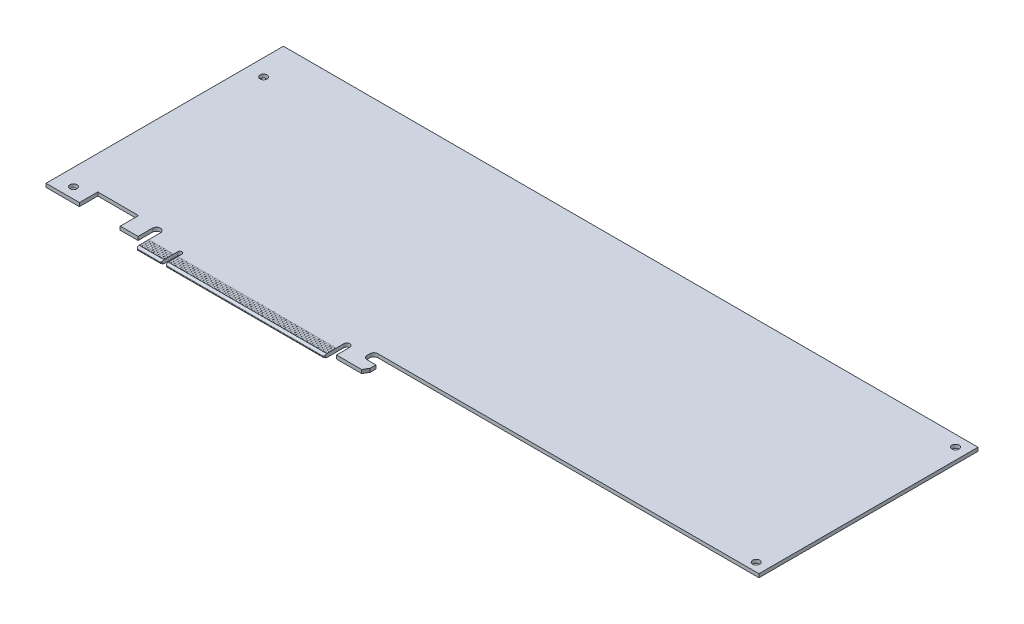
from build123d import *

# Parameters (mm, degrees)
SKETCH1_W                             = 312
SKETCH1_H                             = 111.15
BOSS_EXTRUDE1_DEPTH                   = 1.6
CUT_EXTRUDE1_REACH                    = 3.6
SKETCH2_W                             = 182.7
SKETCH2_H                             = 12.75
SKETCH3_W                             = 0.7
SKETCH3_H                             = 4.2
BOSS_EXTRUDE2_DEPTH                   = 0.035
BOSS_EXTRUDE2_DEPTH_BACK              = 1.635
BOSS_EXTRUDE2_2_DEPTH                 = 0.035
BOSS_EXTRUDE2_2_DEPTH_BACK            = 1.635
BOSS_EXTRUDE2_3_DEPTH                 = 0.035
BOSS_EXTRUDE2_3_DEPTH_BACK            = 1.635
BOSS_EXTRUDE2_4_DEPTH                 = 0.035
BOSS_EXTRUDE2_4_DEPTH_BACK            = 1.635
BOSS_EXTRUDE2_5_DEPTH                 = 0.035
BOSS_EXTRUDE2_5_DEPTH_BACK            = 1.635
BOSS_EXTRUDE2_6_DEPTH                 = 0.035
BOSS_EXTRUDE2_6_DEPTH_BACK            = 1.635
BOSS_EXTRUDE2_7_DEPTH                 = 0.035
BOSS_EXTRUDE2_7_DEPTH_BACK            = 1.635
BOSS_EXTRUDE2_8_DEPTH                 = 0.035
BOSS_EXTRUDE2_8_DEPTH_BACK            = 1.635
BOSS_EXTRUDE2_9_DEPTH                 = 0.035
BOSS_EXTRUDE2_9_DEPTH_BACK            = 1.635
BOSS_EXTRUDE2_10_DEPTH                = 0.035
BOSS_EXTRUDE2_10_DEPTH_BACK           = 1.635
BOSS_EXTRUDE2_11_DEPTH                = 0.035
BOSS_EXTRUDE2_11_DEPTH_BACK           = 1.635
SKETCH4_W                             = 0.7
SKETCH4_H                             = 4.2
BOSS_EXTRUDE3_DEPTH                   = 0.035
BOSS_EXTRUDE3_DEPTH_BACK              = 1.635
LPATTERN1_COUNT                       = 71
LPATTERN1_PITCH                       = 1
SKETCH6_W                             = 1.5875
SKETCH6_H                             = 1.6
F_1_8_0_125_DIAMETER_HOLE1_AT_2_COUNT = 2
F_1_8_0_125_DIAMETER_HOLE1_AT_2_PITCH = 85.4
SKETCH8_W                             = 1.5875
SKETCH8_H                             = 1.601
F_1_8_0_125_DIAMETER_HOLE2_AT_2_COUNT = 2
F_1_8_0_125_DIAMETER_HOLE2_AT_2_PITCH = 89.53
CHAMFER2_SIZE                         = 0.5
BOSS_EXTRUDE4_DEPTH                   = 1.6
CHAMFER3_SIZE                         = 0.6
CHAMFER3_SIZE2                        = 1.3
CHAMFER3_PART_2_SIZE                  = 0.6
CHAMFER3_PART_2_SIZE2                 = 1.3
CHAMFER5_SIZE                         = 1.3
CHAMFER5_SIZE2                        = 0.6
FILLET2_R                             = 0.2


with BuildPart() as part:
    # Sketch1 → Boss-Extrude1 (new body)
    with BuildSketch(Plane(origin=(0, 0, 0), x_dir=(1, 0, 0), z_dir=(0, 1, 0))):
        with Locations((156, 55.575)):
            Rectangle(SKETCH1_W, SKETCH1_H)
    extrude(amount=-BOSS_EXTRUDE1_DEPTH)

    # Sketch2 → Cut-Extrude1 (cut, up to next)
    with BuildSketch(Plane(origin=(0, 0, 0), x_dir=(1, 0, 0), z_dir=(0, 1, 0)), mode=Mode.PRIVATE) as cut_extrude1_sk1:
        with BuildLine():
            Line((0, 4.5), (15, 4.5))
            Line((15, 4.5), (15, 12.75))
            Line((15, 12.75), (33.35, 12.75))
            Line((33.35, 12.75), (33.35, 4.5))
            Line((33.35, 4.5), (41.35, 4.5))
            Line((41.35, 4.5), (41.35, 10.925))
            ThreePointArc((41.35, 10.925), (43.175, 12.75), (45, 10.925))
            Line((45, 10.925), (45, 0))
            Line((45, 0), (0, 0))
            Line((0, 0), (0, 4.5))
        make_face()
    cut_extrude1_tool1 = extrude(cut_extrude1_sk1.sketch, amount=-CUT_EXTRUDE1_REACH, mode=Mode.PRIVATE) & part.part
    add(cut_extrude1_tool1.solids().sort_by_distance((24.712912, 0, -5.236732))[0], mode=Mode.SUBTRACT)
    # Sketch2 → Cut-Extrude1 (cut, up to next)
    with BuildSketch(Plane(origin=(0, 0, 0), x_dir=(1, 0, 0), z_dir=(0, 1, 0)), mode=Mode.PRIVATE) as cut_extrude1_sk2:
        with BuildLine():
            Line((56.2, 0), (56.2, 7.45))
            ThreePointArc((56.2, 7.45), (57.15, 8.4), (58.1, 7.45))
            Line((58.1, 7.45), (58.1, 0))
            Line((58.1, 0), (56.2, 0))
        make_face()
    cut_extrude1_tool2 = extrude(cut_extrude1_sk2.sketch, amount=-CUT_EXTRUDE1_REACH, mode=Mode.PRIVATE) & part.part
    add(cut_extrude1_tool2.solids().sort_by_distance((57.15, 0, -4.100807))[0], mode=Mode.SUBTRACT)
    # Sketch2 → Cut-Extrude1 (cut, up to next)
    with BuildSketch(Plane(origin=(0, 0, 0), x_dir=(1, 0, 0), z_dir=(0, 1, 0)), mode=Mode.PRIVATE) as cut_extrude1_sk3:
        with Locations((220.65, 6.375)):
            Rectangle(SKETCH2_W, SKETCH2_H)
    cut_extrude1_tool3 = extrude(cut_extrude1_sk3.sketch, amount=-CUT_EXTRUDE1_REACH, mode=Mode.PRIVATE) & part.part
    add(cut_extrude1_tool3.solids().sort_by_distance((220.65, 0, -6.375))[0], mode=Mode.SUBTRACT)

    # Sketch6 → 1/8 (0.125) Diameter Hole1 (revolve, cut)
    with BuildSketch(Plane(origin=(7.5, 0, -9.35), x_dir=(0, 0, 1), z_dir=(1, 0, 0))):
        with Locations((0.79375, 0.8)):
            Rectangle(SKETCH6_W, SKETCH6_H)
    f_1_8_0_125_diameter_hole1 = revolve(axis=Axis((7.5, 6.35, -9.35), (0, -1, 0)), mode=Mode.SUBTRACT)

    # 1/8 (0.125) Diameter Hole1 at 2: 1/8 (0.125) Diameter Hole1 ×2
    with Locations(*[(0, 0, -i * F_1_8_0_125_DIAMETER_HOLE1_AT_2_PITCH) for i in range(1, F_1_8_0_125_DIAMETER_HOLE1_AT_2_COUNT)]):
        add(f_1_8_0_125_diameter_hole1, mode=Mode.SUBTRACT)

    # Sketch8 → 1/8 (0.125) Diameter Hole2 (revolve, cut)
    with BuildSketch(Plane(origin=(306.92, 0, -16.6), x_dir=(0, 0, 1), z_dir=(1, 0, 0))):
        with Locations((0.79375, 0.8005)):
            Rectangle(SKETCH8_W, SKETCH8_H)
    f_1_8_0_125_diameter_hole2 = revolve(axis=Axis((306.92, 6.35, -16.6), (0, -1, 0)), mode=Mode.SUBTRACT)

    # 1/8 (0.125) Diameter Hole2 at 2: 1/8 (0.125) Diameter Hole2 ×2
    with Locations(*[(0, 0, -i * F_1_8_0_125_DIAMETER_HOLE2_AT_2_PITCH) for i in range(1, F_1_8_0_125_DIAMETER_HOLE2_AT_2_COUNT)]):
        add(f_1_8_0_125_diameter_hole2, mode=Mode.SUBTRACT)

    # Chamfer2
    chamfer2_edges = [part.edges().sort_by_distance(p)[0] for p in [
        (45, -0.8, 0),
        (58.1, -0.8, 0),
        (56.2, -0.8, 0),
        (129.3, -0.8, 0),
    ]]
    chamfer(chamfer2_edges, length=CHAMFER2_SIZE)

    # Sketch11 → Boss-Extrude4 (add)
    with BuildSketch(Plane(origin=(0, 0, 0), x_dir=(1, 0, 0), z_dir=(0, 1, 0))):
        with BuildLine():
            Line((144.75, 7.95), (140.8, 7.95))
            ThreePointArc((140.8, 7.95), (139.562563133, 8.462563133), (139.05, 9.7))
            Line((139.05, 9.7), (139.05, 11))
            ThreePointArc((139.05, 11), (139.562563133, 12.237436867), (140.8, 12.75))
            Line((140.8, 12.75), (139.05, 12.75))
            Line((139.05, 12.75), (129.3, 12.75))
            Line((129.3, 12.75), (129.3, 8.98))
            ThreePointArc((129.3, 8.98), (130.675, 10.355), (132.05, 8.98))
            Line((132.05, 8.98), (132.05, 2.95))
            Line((132.05, 2.95), (143.35, 2.95))
            Line((143.35, 2.95), (144.75, 5.374871131))
            Line((144.75, 5.374871131), (144.75, 7.95))
        make_face()
    extrude(amount=-BOSS_EXTRUDE4_DEPTH)

    # Chamfer3
    chamfer3_edges = [part.edges().sort_by_distance(p)[0] for p in [
        (93.7, 0, 0),
    ]]
    chamfer3_side = [part.faces().sort_by_distance(p)[0] for p in [
        (93.7, -0.8, 0),
    ]]
    chamfer(chamfer3_edges, length=CHAMFER3_SIZE, length2=CHAMFER3_SIZE2, reference=chamfer3_side[0])

    # Chamfer3 part 2
    chamfer3_part_2_edges = [part.edges().sort_by_distance(p)[0] for p in [
        (50.6, 0, 0),
    ]]
    chamfer3_part_2_side = [part.faces().sort_by_distance(p)[0] for p in [
        (50.6, -0.8, 0),
    ]]
    chamfer(chamfer3_part_2_edges, length=CHAMFER3_PART_2_SIZE, length2=CHAMFER3_PART_2_SIZE2, reference=chamfer3_part_2_side[0])

    # Chamfer5
    chamfer5_edges = [part.edges().sort_by_distance(p)[0] for p in [
        (93.7, -1.6, 0),
        (50.6, -1.6, 0),
    ]]
    chamfer5_side = [part.faces().sort_by_distance(p)[0] for p in [
        (152.851600823, -1.6, -59.623886114),
    ]]
    chamfer(chamfer5_edges, length=CHAMFER5_SIZE, length2=CHAMFER5_SIZE2, reference=chamfer5_side[0])

    # Fillet2
    fillet2_edges = [part.edges().sort_by_distance(p)[0] for p in [
        (93.7, -0.6, 0),
        (50.6, -0.6, 0),
        (93.7, -1, 0),
        (50.6, -1, 0),
    ]]
    fillet(fillet2_edges, radius=FILLET2_R)


with BuildPart() as body_2:
    # Sketch3 → Boss-Extrude2 (new body, two sides)
    with BuildSketch(Plane(origin=(0, 0, 0), x_dir=(1, 0, 0), z_dir=(0, 1, 0))) as boss_extrude2_sk:
        with Locations((45.6, 3.5)):
            Rectangle(SKETCH3_W, SKETCH3_H)
    extrude(amount=BOSS_EXTRUDE2_DEPTH)
    extrude(boss_extrude2_sk.sketch, amount=-BOSS_EXTRUDE2_DEPTH_BACK)


with BuildPart() as body_3:
    # Sketch3 → Boss-Extrude2 2 (new body, two sides)
    with BuildSketch(Plane(origin=(0, 0, 0), x_dir=(1, 0, 0), z_dir=(0, 1, 0))) as boss_extrude2_2_sk:
        with Locations((46.6, 3.5)):
            Rectangle(SKETCH3_W, SKETCH3_H)
    extrude(amount=BOSS_EXTRUDE2_2_DEPTH)
    extrude(boss_extrude2_2_sk.sketch, amount=-BOSS_EXTRUDE2_2_DEPTH_BACK)


with BuildPart() as body_4:
    # Sketch3 → Boss-Extrude2 3 (new body, two sides)
    with BuildSketch(Plane(origin=(0, 0, 0), x_dir=(1, 0, 0), z_dir=(0, 1, 0))) as boss_extrude2_3_sk:
        with Locations((47.6, 3.5)):
            Rectangle(SKETCH3_W, SKETCH3_H)
    extrude(amount=BOSS_EXTRUDE2_3_DEPTH)
    extrude(boss_extrude2_3_sk.sketch, amount=-BOSS_EXTRUDE2_3_DEPTH_BACK)


with BuildPart() as body_5:
    # Sketch3 → Boss-Extrude2 4 (new body, two sides)
    with BuildSketch(Plane(origin=(0, 0, 0), x_dir=(1, 0, 0), z_dir=(0, 1, 0))) as boss_extrude2_4_sk:
        with Locations((48.6, 3.5)):
            Rectangle(SKETCH3_W, SKETCH3_H)
    extrude(amount=BOSS_EXTRUDE2_4_DEPTH)
    extrude(boss_extrude2_4_sk.sketch, amount=-BOSS_EXTRUDE2_4_DEPTH_BACK)


with BuildPart() as body_6:
    # Sketch3 → Boss-Extrude2 5 (new body, two sides)
    with BuildSketch(Plane(origin=(0, 0, 0), x_dir=(1, 0, 0), z_dir=(0, 1, 0))) as boss_extrude2_5_sk:
        with Locations((49.6, 3.5)):
            Rectangle(SKETCH3_W, SKETCH3_H)
    extrude(amount=BOSS_EXTRUDE2_5_DEPTH)
    extrude(boss_extrude2_5_sk.sketch, amount=-BOSS_EXTRUDE2_5_DEPTH_BACK)


with BuildPart() as body_7:
    # Sketch3 → Boss-Extrude2 6 (new body, two sides)
    with BuildSketch(Plane(origin=(0, 0, 0), x_dir=(1, 0, 0), z_dir=(0, 1, 0))) as boss_extrude2_6_sk:
        with Locations((50.6, 3.5)):
            Rectangle(SKETCH3_W, SKETCH3_H)
    extrude(amount=BOSS_EXTRUDE2_6_DEPTH)
    extrude(boss_extrude2_6_sk.sketch, amount=-BOSS_EXTRUDE2_6_DEPTH_BACK)


with BuildPart() as body_8:
    # Sketch3 → Boss-Extrude2 7 (new body, two sides)
    with BuildSketch(Plane(origin=(0, 0, 0), x_dir=(1, 0, 0), z_dir=(0, 1, 0))) as boss_extrude2_7_sk:
        with Locations((51.6, 3.5)):
            Rectangle(SKETCH3_W, SKETCH3_H)
    extrude(amount=BOSS_EXTRUDE2_7_DEPTH)
    extrude(boss_extrude2_7_sk.sketch, amount=-BOSS_EXTRUDE2_7_DEPTH_BACK)


with BuildPart() as body_9:
    # Sketch3 → Boss-Extrude2 8 (new body, two sides)
    with BuildSketch(Plane(origin=(0, 0, 0), x_dir=(1, 0, 0), z_dir=(0, 1, 0))) as boss_extrude2_8_sk:
        with Locations((52.6, 3.5)):
            Rectangle(SKETCH3_W, SKETCH3_H)
    extrude(amount=BOSS_EXTRUDE2_8_DEPTH)
    extrude(boss_extrude2_8_sk.sketch, amount=-BOSS_EXTRUDE2_8_DEPTH_BACK)


with BuildPart() as body_10:
    # Sketch3 → Boss-Extrude2 9 (new body, two sides)
    with BuildSketch(Plane(origin=(0, 0, 0), x_dir=(1, 0, 0), z_dir=(0, 1, 0))) as boss_extrude2_9_sk:
        with Locations((53.6, 3.5)):
            Rectangle(SKETCH3_W, SKETCH3_H)
    extrude(amount=BOSS_EXTRUDE2_9_DEPTH)
    extrude(boss_extrude2_9_sk.sketch, amount=-BOSS_EXTRUDE2_9_DEPTH_BACK)


with BuildPart() as body_11:
    # Sketch3 → Boss-Extrude2 10 (new body, two sides)
    with BuildSketch(Plane(origin=(0, 0, 0), x_dir=(1, 0, 0), z_dir=(0, 1, 0))) as boss_extrude2_10_sk:
        with Locations((54.6, 3.5)):
            Rectangle(SKETCH3_W, SKETCH3_H)
    extrude(amount=BOSS_EXTRUDE2_10_DEPTH)
    extrude(boss_extrude2_10_sk.sketch, amount=-BOSS_EXTRUDE2_10_DEPTH_BACK)


with BuildPart() as body_12:
    # Sketch3 → Boss-Extrude2 11 (new body, two sides)
    with BuildSketch(Plane(origin=(0, 0, 0), x_dir=(1, 0, 0), z_dir=(0, 1, 0))) as boss_extrude2_11_sk:
        with Locations((55.6, 3.5)):
            Rectangle(SKETCH3_W, SKETCH3_H)
    extrude(amount=BOSS_EXTRUDE2_11_DEPTH)
    extrude(boss_extrude2_11_sk.sketch, amount=-BOSS_EXTRUDE2_11_DEPTH_BACK)


with BuildPart() as body_13:
    # Sketch4 → Boss-Extrude3 (new body, two sides)
    with BuildSketch(Plane(origin=(0, 0, 0), x_dir=(1, 0, 0), z_dir=(0, 1, 0))) as boss_extrude3_sk:
        with Locations((58.7, 3.5)):
            Rectangle(SKETCH4_W, SKETCH4_H)
    extrude(amount=BOSS_EXTRUDE3_DEPTH)
    extrude(boss_extrude3_sk.sketch, amount=-BOSS_EXTRUDE3_DEPTH_BACK)

    # LPattern1: body 13 ×71


with BuildPart() as body_13_1:
    add(body_13.part)
    with Locations(*[(i * LPATTERN1_PITCH, 0, 0) for i in range(1, LPATTERN1_COUNT)]):
        add(body_13.part)


solid = Compound([part.part, body_2.part, body_3.part, body_4.part, body_5.part, body_6.part, body_7.part, body_8.part, body_9.part, body_10.part, body_11.part, body_12.part, body_13_1.part])
